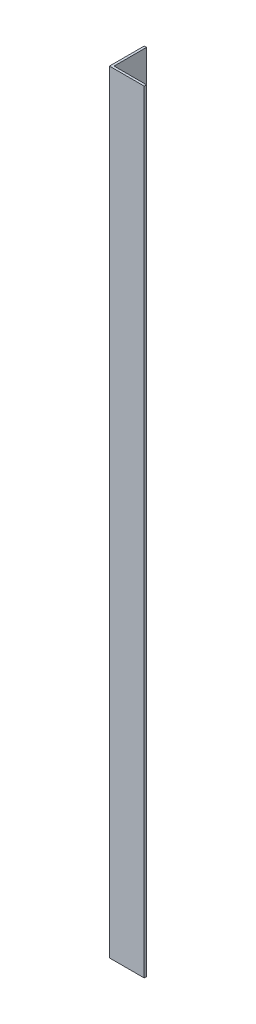
from build123d import *

# Parameters (mm, degrees)
EXTRUDE_1_DEPTH = 1000


with BuildPart() as part:
    # Эскиз1 → Вытянуть-Тонкостенный1 (new body)
    with BuildSketch(Plane(origin=(0, 0, 0), x_dir=(1, 0, 0), z_dir=(0, 1, 0))):
        Polygon((0, 45), (0, 0), (45, 0), (45, 3), (3, 3), (3, 45), align=None)
    extrude(amount=EXTRUDE_1_DEPTH)


solid = part.part
